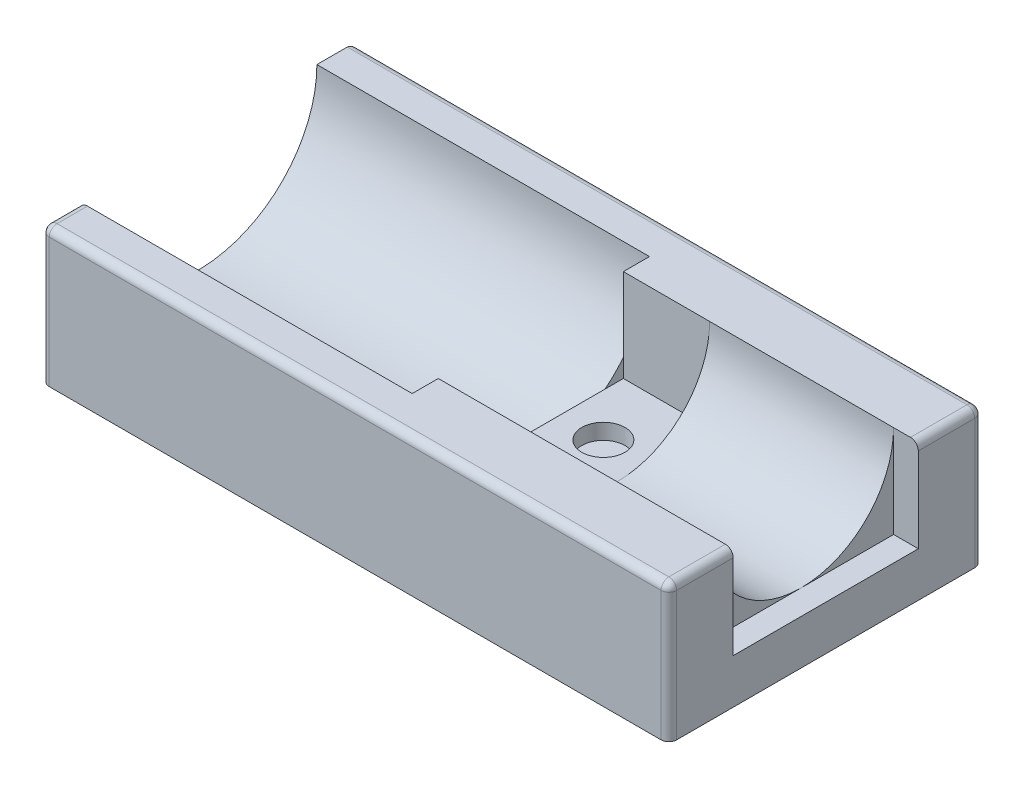
from build123d import *

# Parameters (mm, degrees)
BOSS_EXTRUDE1_DEPTH = 88.89999999999999
SKETCH2_R           = 29.97200000000001
CUT_EXTRUDE1_DEPTH  = 203.2
CUT_EXTRUDE2_DEPTH  = 8.001
SKETCH4_W           = 59.943999999999946
SKETCH4_H           = 29.972
CUT_EXTRUDE3_DEPTH  = 27.94
SKETCH5_R           = 38.417500000000004
CUT_EXTRUDE4_DEPTH  = 107.696
CUT_EXTRUDE5_DEPTH  = 5.08
SKETCH7_W           = 203.19999999999996
SKETCH7_H           = 6.349999999999999
BOSS_EXTRUDE2_DEPTH = 38.1
FILLET1_R           = 2.54
CUT_EXTRUDE6_DEPTH  = 44.449999999999996


with BuildPart() as part:
    # Sketch1 → Boss-Extrude1 (new body)
    with BuildSketch(Plane(origin=(0, 0, 0), x_dir=(1, 0, 0), z_dir=(0, 1, 0))):
        Polygon((0, 0), (203.2, 0), (203.2, -101.6), (1.244e-14, -101.6), align=None)
    extrude(amount=BOSS_EXTRUDE1_DEPTH)

    # Sketch2 → Cut-Extrude1 (cut)
    with BuildSketch(Plane(origin=(203.2, 0, 0), x_dir=(-2.2e-16, 0, -1), z_dir=(1, 0, -2.2e-16))):
        with Locations((-50.8, 88.89999999999999)):
            Circle(SKETCH2_R)
    extrude(amount=-CUT_EXTRUDE1_DEPTH, mode=Mode.SUBTRACT)

    # Sketch3 → Cut-Extrude2 (cut)
    with BuildSketch(Plane(origin=(203.2, 0, 0), x_dir=(-2.2e-16, 0, -1), z_dir=(1, 0, -2.2e-16))):
        Polygon((-20.82800000000002, 118.87199999999997), (-80.77199999999996, 118.87199999999996), (-80.77199999999996, 58.928000000000004), (-20.828000000000007, 58.928000000000004), align=None)
    extrude(amount=-CUT_EXTRUDE2_DEPTH, mode=Mode.SUBTRACT)

    # Sketch4 → Cut-Extrude3 (cut)
    with BuildSketch(Plane(origin=(135.636, 0, 0), x_dir=(-2.2e-16, 0, -1), z_dir=(1, 0, -2.2e-16))):
        with Locations((-50.800000000000004, 73.914)):
            Rectangle(SKETCH4_W, SKETCH4_H)
    extrude(amount=-CUT_EXTRUDE3_DEPTH, mode=Mode.SUBTRACT)

    # Sketch5 → Cut-Extrude4 (cut)
    with BuildSketch(Plane.ZY):
        with Locations((50.8, 88.89999999999999)):
            Circle(SKETCH5_R)
    extrude(amount=-CUT_EXTRUDE4_DEPTH, mode=Mode.SUBTRACT)

    # Sketch6 → Cut-Extrude5 (cut)
    with BuildSketch(Plane(origin=(0, 58.928000000000004, 0), x_dir=(1, 0, 0), z_dir=(0, 1, 0))):
        with BuildLine():
            ThreePointArc((121.66599999999983, -34.29000000000002), (114.68100000000004, -41.275000000000006), (121.66599999999983, -48.25999999999999))
            Line((121.66600000000003, -48.25999999999999), (121.66600000000003, -34.29000000000002))
        make_face()
        with BuildLine():
            Line((121.66600000000003, -34.29000000000002), (121.66600000000003, -48.25999999999999))
            ThreePointArc((121.66599999999983, -48.25999999999999), (126.60514086658797, -46.214140866588096), (128.651, -41.275000000000006))
            ThreePointArc((128.651, -41.275000000000006), (126.60514086658797, -36.335859133411915), (121.66599999999983, -34.29000000000002))
        make_face()
    extrude(amount=-CUT_EXTRUDE5_DEPTH, mode=Mode.SUBTRACT)

    # Sketch7 → Boss-Extrude2 (add)
    with BuildSketch(Plane.XY.offset(101.6)):
        with Locations((101.59999999999998, 3.1749999999999994)):
            Rectangle(SKETCH7_W, SKETCH7_H)
    extrude(amount=BOSS_EXTRUDE2_DEPTH)

    # Fillet1
    fillet1_edges = [part.edges().sort_by_distance(p)[0] for p in [
        (101.6, 6.35, 101.6),
        (0, 6.35, 120.64999999999999),
        (203.2, 6.35, 120.64999999999999),
        (0, 44.449999999999996, 0),
        (1.168e-14, 88.89999999999999, 95.40875),
        (1.244e-14, 47.625, 101.6),
        (101.6, 88.89999999999999, 0),
        (203.2, 44.449999999999996, 0),
        (203.2, 88.89999999999999, 10.413999999999994),
        (203.2, 88.89999999999999, 91.186),
        (101.6, 88.89999999999999, 101.6),
        (203.2, 47.625, 101.6),
    ]]
    fillet(fillet1_edges, radius=FILLET1_R)

    # Sketch8 → Cut-Extrude6 (cut)
    with BuildSketch(Plane.XZ):
        Polygon((0, 139.7), (203.2, 139.7), (203.20000000000002, -1.73e-15), (1.711e-14, 0), align=None)
    extrude(amount=-CUT_EXTRUDE6_DEPTH, mode=Mode.SUBTRACT)


solid = part.part
